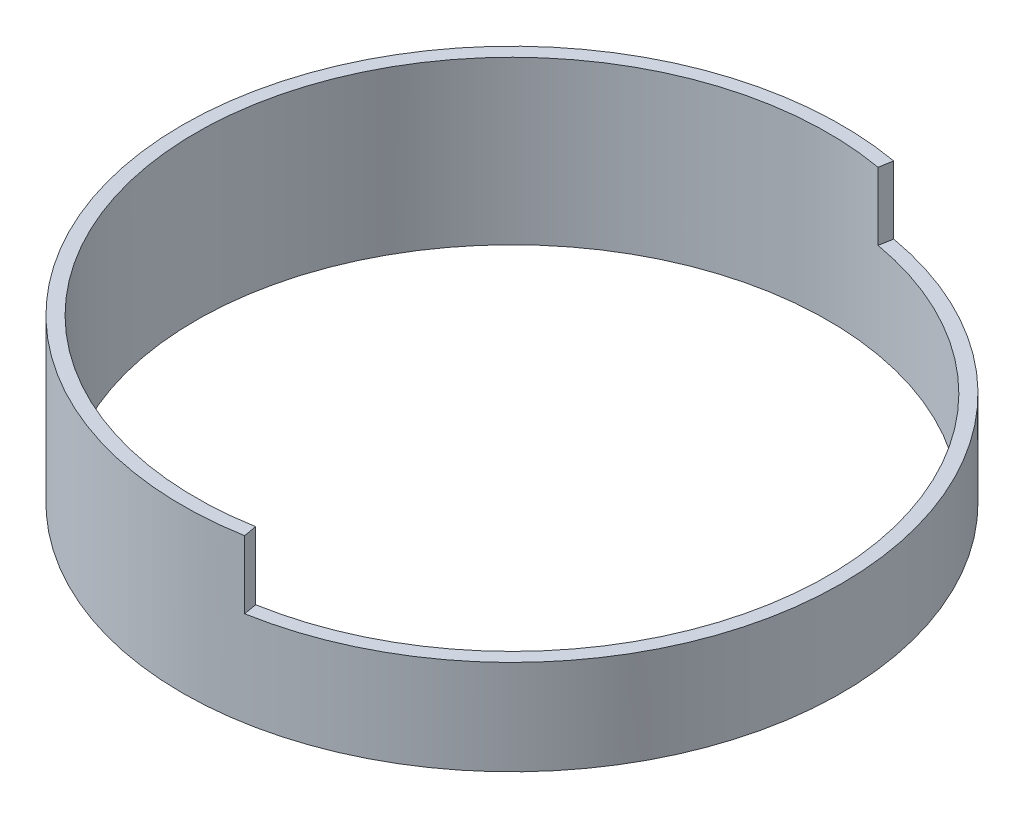
from build123d import *

# Parameters (mm, degrees)
BOSS_EXTRUDE1_DEPTH = 38.1
SKETCH1_3_R         = 77.31506
SKETCH1_3_R_2       = 74.14006
BOSS_EXTRUDE2_DEPTH = 22.225


with BuildPart() as part:
    # Sketch1 → Boss-Extrude1 (new body)
    with BuildSketch(Plane(origin=(0, 0, 0), x_dir=(1, 0, 0), z_dir=(0, 1, 0))):
        with BuildLine():
            Line((13.425619275, -76.140470513), (12.874286311, -73.013705897))
            ThreePointArc((12.874286311, -73.013705897), (-74.14006, 0), (12.874286311, 73.013705897))
            Line((12.874286311, 73.013705897), (13.425619275, 76.140470513))
            ThreePointArc((13.425619275, 76.140470513), (-77.31506, 0), (13.425619275, -76.140470513))
        make_face()
    extrude(amount=BOSS_EXTRUDE1_DEPTH)

    # Sketch1_3 → Boss-Extrude2 (add)
    with BuildSketch(Plane(origin=(0, 0, 0), x_dir=(1, 0, 0), z_dir=(0, 1, 0))):
        Circle(SKETCH1_3_R)
        Circle(SKETCH1_3_R_2, mode=Mode.SUBTRACT)
    extrude(amount=BOSS_EXTRUDE2_DEPTH)


solid = part.part
